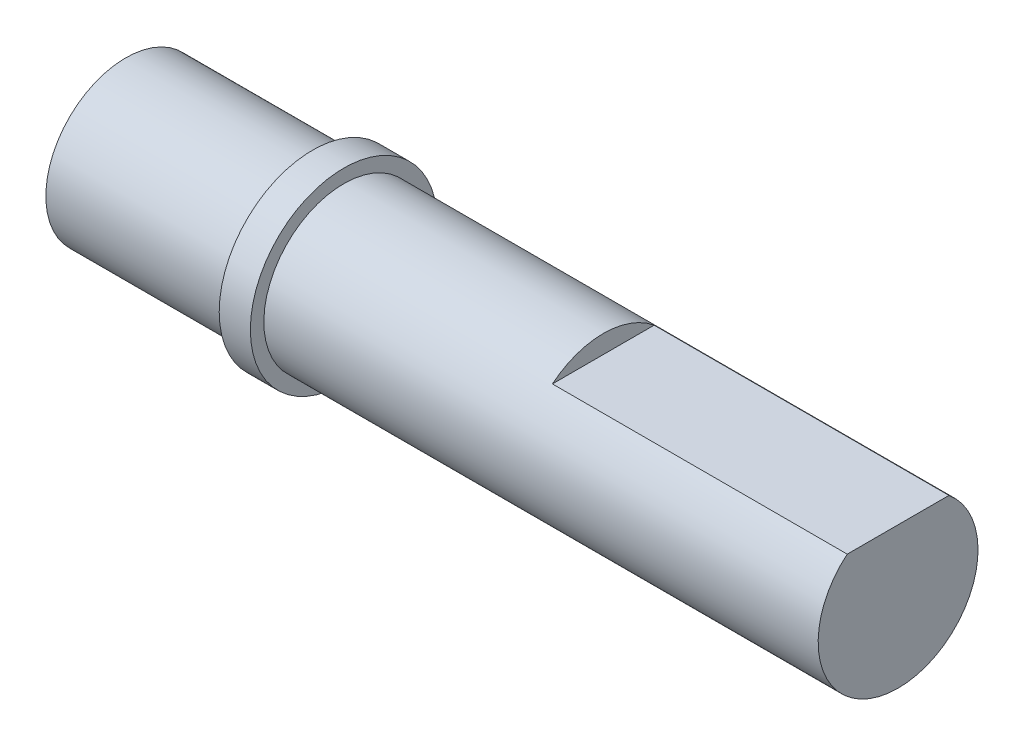
from build123d import *

# Parameters (mm, degrees)
BOSS_EXTRUDE1_DEPTH = 28.2
SKETCH9_6_R         = 4.5
SKETCH9_6_R_2       = 3.85
BOSS_EXTRUDE2_DEPTH = 1.5
BOSS_EXTRUDE3_DEPTH = 14
BOSS_EXTRUDE4_DEPTH = 9


with BuildPart() as part:
    # Sketch9 → Boss-Extrude1 (new body)
    with BuildSketch(Plane(origin=(0, 0, 0), x_dir=(0, 0, -1), z_dir=(1, 0, 0))):
        with BuildLine():
            Line((2.45, 2.969848481), (-2.45, 2.969848481))
            ThreePointArc((-2.45, 2.969848481), (-1.641645516, -3.48245603), (3.85, 0))
            ThreePointArc((3.85, 0), (3.48245603, 1.641645516), (2.45, 2.969848481))
        make_face()
    extrude(amount=BOSS_EXTRUDE1_DEPTH)

    # Sketch9_6 → Boss-Extrude2 (add)
    with BuildSketch(Plane(origin=(0, 0, 0), x_dir=(0, 0, -1), z_dir=(1, 0, 0))):
        Circle(SKETCH9_6_R)
        Circle(SKETCH9_6_R_2, mode=Mode.SUBTRACT)
    extrude(amount=BOSS_EXTRUDE2_DEPTH)

    # Sketch9_7 → Boss-Extrude3 (add)
    with BuildSketch(Plane(origin=(0, 0, 0), x_dir=(0, 0, -1), z_dir=(1, 0, 0))):
        with BuildLine():
            ThreePointArc((2.45, 2.969848481), (0, 3.85), (-2.45, 2.969848481))
            Line((-2.45, 2.969848481), (2.45, 2.969848481))
        make_face()
        with BuildLine():
            Line((2.45, 2.969848481), (-2.45, 2.969848481))
            ThreePointArc((-2.45, 2.969848481), (-1.641645516, -3.48245603), (3.85, 0))
            ThreePointArc((3.85, 0), (3.48245603, 1.641645516), (2.45, 2.969848481))
        make_face()
    extrude(amount=BOSS_EXTRUDE3_DEPTH)

    # Sketch9_8 → Boss-Extrude4 (add)
    with BuildSketch(Plane(origin=(0, 0, 0), x_dir=(0, 0, -1), z_dir=(1, 0, 0))):
        with BuildLine():
            ThreePointArc((2.45, 2.969848481), (0, 3.85), (-2.45, 2.969848481))
            Line((-2.45, 2.969848481), (2.45, 2.969848481))
        make_face()
        with BuildLine():
            Line((2.45, 2.969848481), (-2.45, 2.969848481))
            ThreePointArc((-2.45, 2.969848481), (-1.641645516, -3.48245603), (3.85, 0))
            ThreePointArc((3.85, 0), (3.48245603, 1.641645516), (2.45, 2.969848481))
        make_face()
    extrude(amount=-BOSS_EXTRUDE4_DEPTH)


solid = part.part
